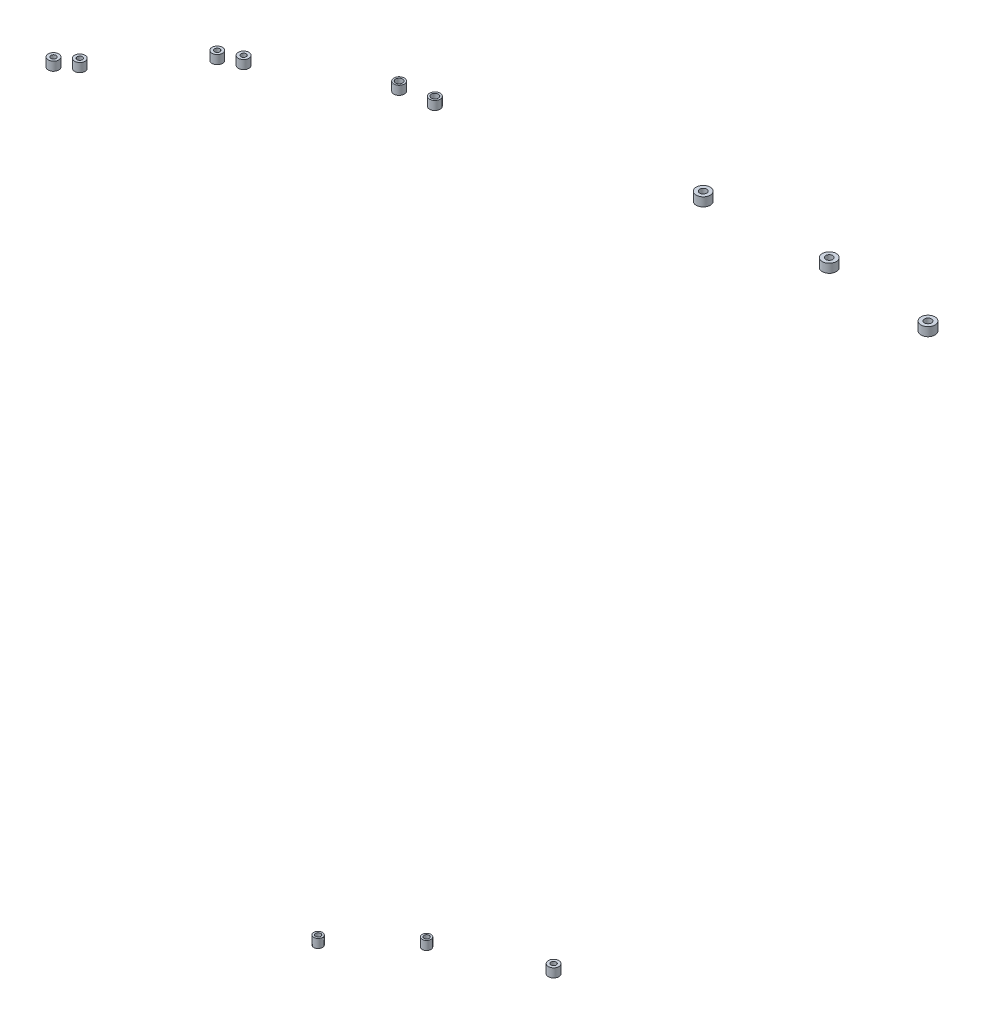
from build123d import *

# Parameters (mm, degrees)
SZKIC1_R                      = 3
SZKIC1_R_2                    = 1.5
DODANIE_WYCI_GNI_CIE1_DEPTH   = 5
DODANIE_WYCI_GNI_CIE1_2_DEPTH = 5
DODANIE_WYCI_GNI_CIE1_3_DEPTH = 5
DODANIE_WYCI_GNI_CIE1_4_DEPTH = 5
SZKIC1_R_3                    = 2
DODANIE_WYCI_GNI_CIE1_5_DEPTH = 5
DODANIE_WYCI_GNI_CIE1_6_DEPTH = 5
SZKIC1_R_4                    = 4
DODANIE_WYCI_GNI_CIE1_7_DEPTH = 5
DODANIE_WYCI_GNI_CIE1_8_DEPTH = 5
DODANIE_WYCI_GNI_CIE1_9_DEPTH = 5
SZKIC2_R                      = 2.5
SZKIC2_R_2                    = 1.5
DODANIE_WYCI_GNI_CIE2_DEPTH   = 5
SZKIC2_R_3                    = 3
DODANIE_WYCI_GNI_CIE2_2_DEPTH = 5
DODANIE_WYCI_GNI_CIE2_3_DEPTH = 5


with BuildPart() as part:
    # Szkic1 → Dodanie-wyciągnięcie1 (new body)
    with BuildSketch(Plane(origin=(0, 700, 0), x_dir=(1, 0, 0), z_dir=(0, 1, 0))):
        with Locations((-474.446759549, -382.68779999)):
            Circle(SZKIC1_R)
        with Locations((-474.446759549, -382.68779999)):
            Circle(SZKIC1_R_2, mode=Mode.SUBTRACT)
    extrude(amount=DODANIE_WYCI_GNI_CIE1_DEPTH)


with BuildPart() as body_2:
    # Szkic1 → Dodanie-wyci_gni_cie1 2 (new body)
    with BuildSketch(Plane(origin=(0, 700, 0), x_dir=(1, 0, 0), z_dir=(0, 1, 0))):
        with Locations((-466.308050674, -375.85941501)):
            Circle(SZKIC1_R)
        with Locations((-466.308050674, -375.85941501)):
            Circle(SZKIC1_R_2, mode=Mode.SUBTRACT)
    extrude(amount=DODANIE_WYCI_GNI_CIE1_2_DEPTH)


with BuildPart() as body_3:
    # Szkic1 → Dodanie-wyci_gni_cie1 3 (new body)
    with BuildSketch(Plane(origin=(0, 700, 0), x_dir=(1, 0, 0), z_dir=(0, 1, 0))):
        with Locations((-431.039698402, -332.774189517)):
            Circle(SZKIC1_R)
        with Locations((-431.039698402, -332.774189517)):
            Circle(SZKIC1_R_2, mode=Mode.SUBTRACT)
    extrude(amount=DODANIE_WYCI_GNI_CIE1_3_DEPTH)


with BuildPart() as body_4:
    # Szkic1 → Dodanie-wyci_gni_cie1 4 (new body)
    with BuildSketch(Plane(origin=(0, 700, 0), x_dir=(1, 0, 0), z_dir=(0, 1, 0))):
        with Locations((-421.090050281, -327.725114352)):
            Circle(SZKIC1_R)
        with Locations((-421.090050281, -327.725114352)):
            Circle(SZKIC1_R_2, mode=Mode.SUBTRACT)
    extrude(amount=DODANIE_WYCI_GNI_CIE1_4_DEPTH)


with BuildPart() as body_5:
    # Szkic1 → Dodanie-wyci_gni_cie1 5 (new body)
    with BuildSketch(Plane(origin=(0, 700, 0), x_dir=(1, 0, 0), z_dir=(0, 1, 0))):
        with Locations((-364.051137421, -296.101801859)):
            Circle(SZKIC1_R)
        with Locations((-364.051137421, -296.101801859)):
            Circle(SZKIC1_R_3, mode=Mode.SUBTRACT)
    extrude(amount=DODANIE_WYCI_GNI_CIE1_5_DEPTH)


with BuildPart() as body_6:
    # Szkic1 → Dodanie-wyci_gni_cie1 6 (new body)
    with BuildSketch(Plane(origin=(0, 700, 0), x_dir=(1, 0, 0), z_dir=(0, 1, 0))):
        with Locations((-346.389872513, -293.396246383)):
            Circle(SZKIC1_R)
        with Locations((-346.389872513, -293.396246383)):
            Circle(SZKIC1_R_3, mode=Mode.SUBTRACT)
    extrude(amount=DODANIE_WYCI_GNI_CIE1_6_DEPTH)


with BuildPart() as body_7:
    # Szkic1 → Dodanie-wyci_gni_cie1 7 (new body)
    with BuildSketch(Plane(origin=(0, 700, 0), x_dir=(1, 0, 0), z_dir=(0, 1, 0))):
        with Locations((-223.024834581, -263.802212936)):
            Circle(SZKIC1_R_4)
        with Locations((-223.024834581, -263.802212936)):
            Circle(SZKIC1_R_3, mode=Mode.SUBTRACT)
    extrude(amount=DODANIE_WYCI_GNI_CIE1_7_DEPTH)


with BuildPart() as body_8:
    # Szkic1 → Dodanie-wyci_gni_cie1 8 (new body)
    with BuildSketch(Plane(origin=(0, 700, 0), x_dir=(1, 0, 0), z_dir=(0, 1, 0))):
        with Locations((-154.344703344, -260.643821632)):
            Circle(SZKIC1_R_4)
        with Locations((-154.344703344, -260.643821632)):
            Circle(SZKIC1_R_3, mode=Mode.SUBTRACT)
    extrude(amount=DODANIE_WYCI_GNI_CIE1_8_DEPTH)


with BuildPart() as body_9:
    # Szkic1 → Dodanie-wyci_gni_cie1 9 (new body)
    with BuildSketch(Plane(origin=(0, 700, 0), x_dir=(1, 0, 0), z_dir=(0, 1, 0))):
        with Locations((-94.909521544, -263.802212936)):
            Circle(SZKIC1_R_4)
        with Locations((-94.909521544, -263.802212936)):
            Circle(SZKIC1_R_3, mode=Mode.SUBTRACT)
    extrude(amount=DODANIE_WYCI_GNI_CIE1_9_DEPTH)


with BuildPart() as body_10:
    # Szkic2 → Dodanie-wyciągnięcie2 (new body)
    with BuildSketch(Plane.XZ.offset(-294.7)):
        with Locations((-370.956911026, 335.367132453)):
            Circle(SZKIC2_R)
        with Locations((-370.956911026, 335.367132453)):
            Circle(SZKIC2_R_2, mode=Mode.SUBTRACT)
    extrude(amount=-DODANIE_WYCI_GNI_CIE2_DEPTH)


with BuildPart() as body_11:
    # Szkic2 → Dodanie-wyci_gni_cie2 2 (new body)
    with BuildSketch(Plane.XZ.offset(-294.7)):
        with Locations((-289.68705591, 282.424125213)):
            Circle(SZKIC2_R_3)
        with Locations((-289.68705591, 282.424125213)):
            Circle(SZKIC2_R_2, mode=Mode.SUBTRACT)
    extrude(amount=-DODANIE_WYCI_GNI_CIE2_2_DEPTH)


with BuildPart() as body_12:
    # Szkic2 → Dodanie-wyci_gni_cie2 3 (new body)
    with BuildSketch(Plane.XZ.offset(-294.7)):
        with Locations((-339.082998521, 305.429754445)):
            Circle(SZKIC2_R)
        with Locations((-339.082998521, 305.429754445)):
            Circle(SZKIC2_R_2, mode=Mode.SUBTRACT)
    extrude(amount=-DODANIE_WYCI_GNI_CIE2_3_DEPTH)


solid = Compound([part.part, body_2.part, body_3.part, body_4.part, body_5.part, body_6.part, body_7.part, body_8.part, body_9.part, body_10.part, body_11.part, body_12.part])
